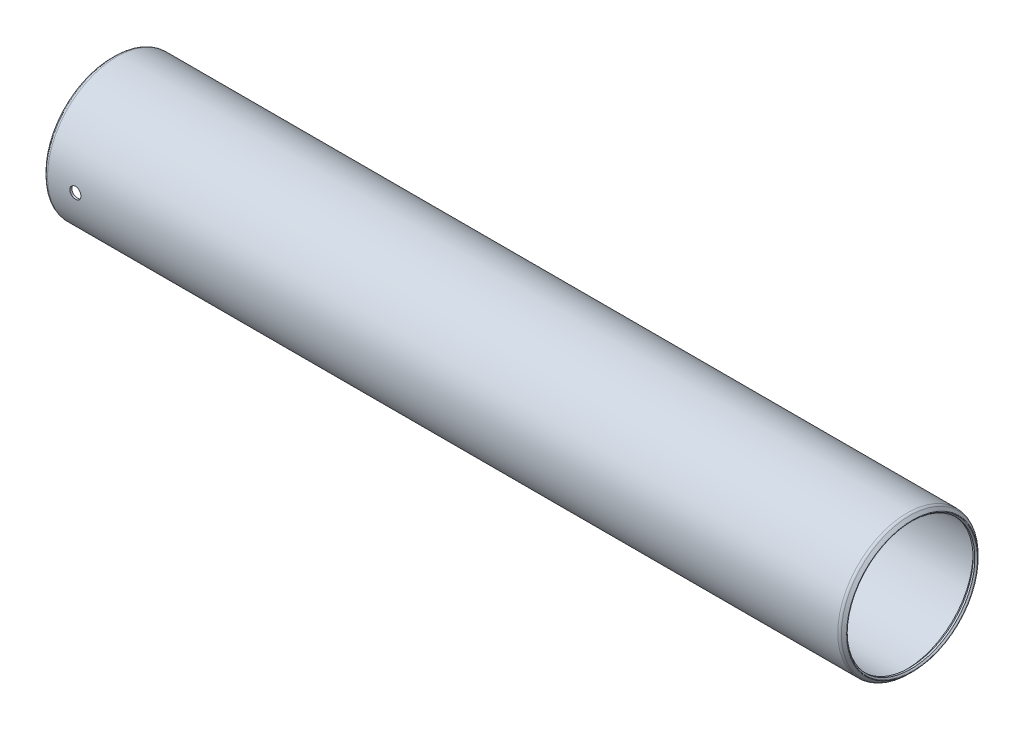
from build123d import *

# Parameters (mm, degrees)
SKETCH2_R          = 1.5875
CUT_EXTRUDE1_DEPTH = 19.76755


with BuildPart() as part:
    # Sketch1 → Revolve1 (revolve)
    with BuildSketch(Plane.XY):
        with BuildLine():
            Line((-0.882617928, 18.554667928), (-0.508, 18.18005))
            Line((-0.508, 18.18005), (0, 18.18005))
            Line((0, 18.18005), (1.016, 19.19605))
            Line((1.016, 19.19605), (225.1202, 19.19605))
            Line((225.1202, 19.19605), (226.1362, 18.18005))
            Line((226.1362, 18.18005), (226.6442, 18.18005))
            Line((226.6442, 18.18005), (227.018817928, 18.554667928))
            ThreePointArc((227.018817928, 18.554667928), (227.056015367, 18.64447049), (227.018817928, 18.734273051))
            Line((227.018817928, 18.734273051), (226.28312049, 19.46997049))
            ThreePointArc((226.28312049, 19.46997049), (225.953506367, 19.690211605), (225.5647, 19.76755))
            Line((225.5647, 19.76755), (0.5715, 19.76755))
            ThreePointArc((0.5715, 19.76755), (0.182693633, 19.690211605), (-0.14692049, 19.46997049))
            Line((-0.14692049, 19.46997049), (-0.882617928, 18.734273051))
            ThreePointArc((-0.882617928, 18.734273051), (-0.919815367, 18.64447049), (-0.882617928, 18.554667928))
        make_face()
    revolve(axis=Axis((226.1362, 0, 0), (-1, 0, 0)))

    # Sketch2 → Cut-Extrude1 (cut)
    with BuildSketch(Plane.XY):
        with Locations((8.509, 0)):
            Circle(SKETCH2_R)
    extrude(amount=CUT_EXTRUDE1_DEPTH, mode=Mode.SUBTRACT)


solid = part.part
